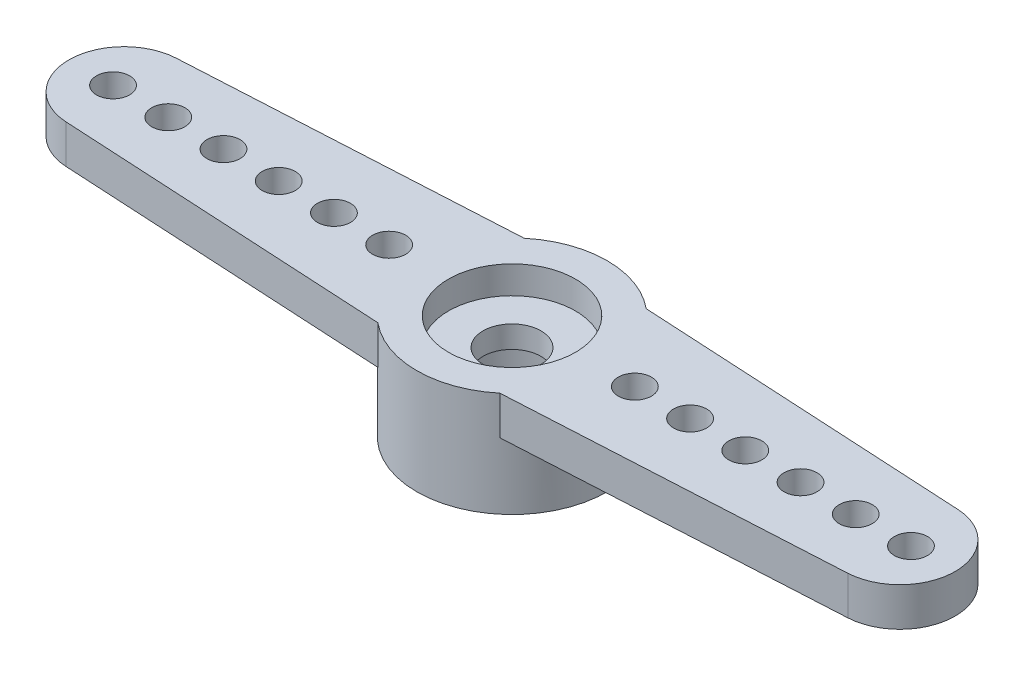
from build123d import *

# Parameters (mm, degrees)
RESSALTO_EXTRUS_O1_DEPTH = 1.4
ESBO_O2_R                = 3.45
RESSALTO_EXTRUS_O2_DEPTH = 2.4
FURO4_D                  = 1.2
PADR_O_LINEAR1_COUNT     = 6
PADR_O_LINEAR1_PITCH     = 2
PADR_OCIRCULAR2_COUNT    = 2
PADR_OCIRCULAR2_COPY_1_D = 1.2
PADR_OCIRCULAR2_COPY_2_D = 1.2
PADR_OCIRCULAR2_COPY_3_D = 1.2
PADR_OCIRCULAR2_COPY_4_D = 1.2
PADR_OCIRCULAR2_COPY_5_D = 1.2
FURO1_D                  = 4.95
FURO1_DEPTH              = 2
FURO2_D                  = 4.6
FURO2_DEPTH              = 1
FURO3_D                  = 2.1
RESSALTO_EXTRUS_O3_DEPTH = 2


with BuildPart() as part:
    # Esboço1 → Ressalto-extrusão1 (new body)
    with BuildSketch(Plane(origin=(0, 0, 0), x_dir=(1, 0, 0), z_dir=(0, 1, 0))):
        with BuildLine():
            Line((-14.159121967, 1.99702088), (-2.209072203, 2.65))
            ThreePointArc((-2.209072203, 2.65), (3.45, 0), (-2.209072203, -2.65))
            Line((-2.209072203, -2.65), (-14.159121967, -1.99702088))
            ThreePointArc((-14.159121967, -1.99702088), (-16.05, 0), (-14.159121967, 1.99702088))
        make_face()
    ressalto_extrus_o1 = extrude(amount=-RESSALTO_EXTRUS_O1_DEPTH)

    # Esboço2 → Ressalto-extrusão2 (add)
    with BuildSketch(Plane.XZ.offset(1.4)):
        Circle(ESBO_O2_R)
    extrude(amount=RESSALTO_EXTRUS_O2_DEPTH)

    # Furo4 (through all)
    with Locations(Plane(origin=(0, 0, 0), x_dir=(1, 0, 0), z_dir=(0, 1, 0))):
        with Locations((-14.45, 0)):
            furo4 = Hole(FURO4_D / 2)

    # Padrão linear1: Furo4 ×6
    with Locations(*[(i * PADR_O_LINEAR1_PITCH, 0, 0) for i in range(1, PADR_O_LINEAR1_COUNT)]):
        add(furo4, mode=Mode.SUBTRACT)

    # PadrãoCircular2: Ressalto-extrusão1, Furo4 ×2 about axis
    padr_ocircular2_axis = Axis((0, 0, 0), (0, 1, 0))
    for i in range(1, PADR_OCIRCULAR2_COUNT):
        add(ressalto_extrus_o1.rotate(padr_ocircular2_axis, i * 360 / PADR_OCIRCULAR2_COUNT))
        add(furo4.rotate(padr_ocircular2_axis, i * 360 / PADR_OCIRCULAR2_COUNT), mode=Mode.SUBTRACT)

    # PadrãoCircular2 copy 1 (through all)
    with Locations(Plane(origin=(-2, 0, 0), x_dir=(-1, 0, 0), z_dir=(0, 1, 0))):
        with Locations((-14.45, 0)):
            Hole(PADR_OCIRCULAR2_COPY_1_D / 2)

    # PadrãoCircular2 copy 2 (through all)
    with Locations(Plane(origin=(-4, 0, 0), x_dir=(-1, 0, 0), z_dir=(0, 1, 0))):
        with Locations((-14.45, 0)):
            Hole(PADR_OCIRCULAR2_COPY_2_D / 2)

    # PadrãoCircular2 copy 3 (through all)
    with Locations(Plane(origin=(-6, 0, 0), x_dir=(-1, 0, 0), z_dir=(0, 1, 0))):
        with Locations((-14.45, 0)):
            Hole(PADR_OCIRCULAR2_COPY_3_D / 2)

    # PadrãoCircular2 copy 4 (through all)
    with Locations(Plane(origin=(-8, 0, 0), x_dir=(-1, 0, 0), z_dir=(0, 1, 0))):
        with Locations((-14.45, 0)):
            Hole(PADR_OCIRCULAR2_COPY_4_D / 2)

    # PadrãoCircular2 copy 5 (through all)
    with Locations(Plane(origin=(-10, 0, 0), x_dir=(-1, 0, 0), z_dir=(0, 1, 0))):
        with Locations((-14.45, 0)):
            Hole(PADR_OCIRCULAR2_COPY_5_D / 2)

    # Furo1
    with Locations(Plane(origin=(0, -3.8, 0), x_dir=(-1, 0, 0), z_dir=(0, -1, 0))):
        with Locations((0, 0)):
            Hole(FURO1_D / 2, depth=FURO1_DEPTH)

    # Furo2
    with Locations(Plane(origin=(0, 0, 0), x_dir=(1, 0, 0), z_dir=(0, 1, 0))):
        with Locations((0, 0)):
            Hole(FURO2_D / 2, depth=FURO2_DEPTH)

    # Furo3 (through all)
    with Locations(Plane(origin=(0, 0, 0), x_dir=(1, 0, 0), z_dir=(0, 1, 0))):
        with Locations((0, 0)):
            Hole(FURO3_D / 2)

    # Esboço11 → Ressalto-extrusão3 (add)
    with BuildSketch(Plane.XZ.offset(3.8)):
        with BuildLine():
            Line((-0.098056786, 2.473056786), (0, 2.375))
            Line((0, 2.375), (0.098056786, 2.473056786))
            ThreePointArc((0.098056786, 2.473056786), (0, 2.475), (-0.098056786, 2.473056786))
        make_face()
    extrude(amount=-RESSALTO_EXTRUS_O3_DEPTH)


solid = part.part
